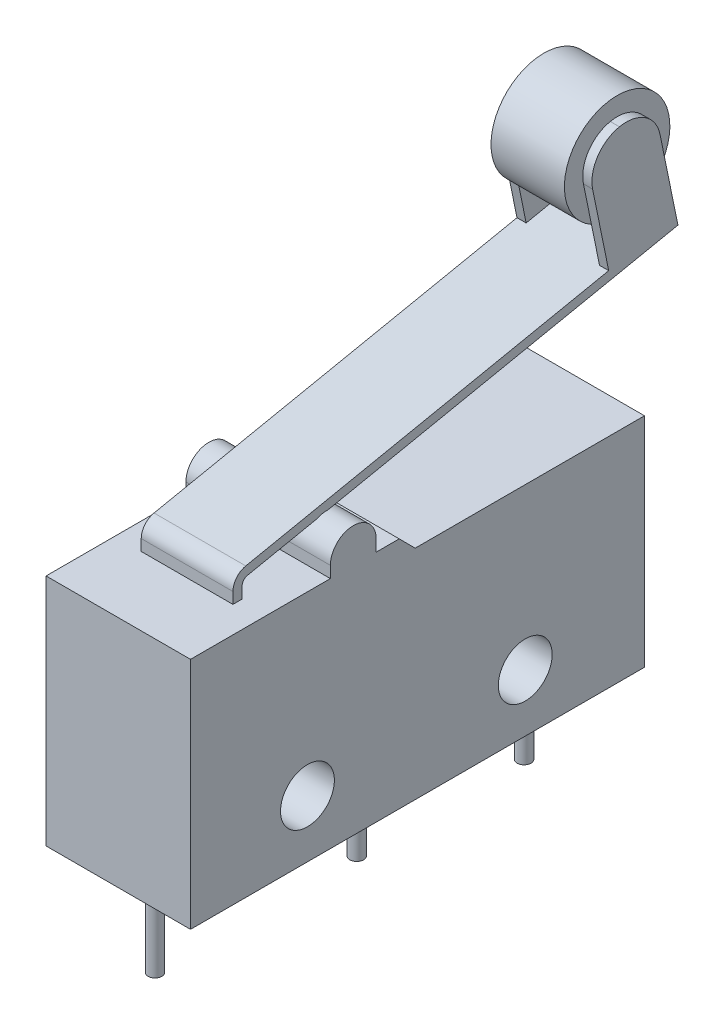
from build123d import *

# Parameters (mm, degrees)
ESQUISSE1_R      = 1.175
EXTRUSION1_DEPTH = 6.3
ESQUISSE2_R      = 0.3
EXTRUSION2_DEPTH = 4
ESQUISSE7_W      = 4
ESQUISSE7_H      = 0.4
ESQUISSE9_W      = 0.4
ESQUISSE9_H      = 3
EXTRUSION3_DEPTH = 5
CONG_1_R         = 1.499
ESQUISSE10_R     = 2.3
EXTRUSION4_DEPTH = 3.2


with BuildPart() as part:
    # Esquisse1 → Extrusion1 (new body)
    with BuildSketch(Plane(origin=(0, 0, 0), x_dir=(0, 0, -1), z_dir=(1, 0, 0))):
        with BuildLine():
            Line((9.8, 9.5), (19.8, 9.5))
            Line((19.8, 9.5), (19.8, 0))
            Line((19.8, 0), (0, 0))
            Line((0, 0), (0, 10.2))
            Line((0, 10.2), (6.1, 10.2))
            Line((6.1, 10.2), (6.1, 10.7))
            ThreePointArc((6.1, 10.7), (7.1, 11.7), (8.1, 10.7))
            Line((8.1, 10.7), (8.1, 10.2))
            Line((8.1, 10.2), (9.102549487, 10.2))
            Line((9.102549487, 10.2), (9.8, 9.5))
        make_face()
        with Locations((14.6, 2.5)):
            Circle(ESQUISSE1_R, mode=Mode.SUBTRACT)
        with Locations((5.1, 2.5)):
            Circle(ESQUISSE1_R, mode=Mode.SUBTRACT)
    extrude(amount=EXTRUSION1_DEPTH)

    # Esquisse2 → Extrusion2 (add)
    with BuildSketch(Plane.XZ):
        with Locations(Location((3.15, -1.6, 0), (0, 0, 90))):  # turned: the seam where the file's is
            Circle(ESQUISSE2_R)
        with Locations(Location((3.15, -10.4, 0), (0, 0, 90))):  # turned: the seam where the file's is
            Circle(ESQUISSE2_R)
        with Locations(Location((3.15, -17.7, 0), (0, 0, 90))):  # turned: the seam where the file's is
            Circle(ESQUISSE2_R)
    extrude(amount=EXTRUSION2_DEPTH)

    # Balayage1: sweep along a path in Esquisse8
    with BuildLine(Plane(origin=(3.15, 0, 0), x_dir=(0, 0, -1), z_dir=(1, 0, 0))) as balayage1_path:
        Line((3.2, 10.2), (3.2, 10.687364871))
        ThreePointArc((3.2, 10.687364871), (3.312633707, 11.003509387), (3.59978942, 11.177219788))
        Line((3.59978942, 11.177219788), (22.368561812, 15.01678431))
    # Esquisse7 → Balayage1 (sweep)
    with BuildSketch(Plane(origin=(0, 10.2, 0), x_dir=(-1, 0, 0), z_dir=(0, 1, 0))):
        with Locations((-3.15, -3.2)):
            Rectangle(ESQUISSE7_W, ESQUISSE7_H)
    sweep(path=balayage1_path.line)

    # Esquisse9 → Extrusion3 (add)
    with BuildSketch(Plane(origin=(0, 10.217352882, 2.090183887), x_dir=(-1, 0, 0), z_dir=(0, 0.979709834, 0.200421159))):
        with Locations((-4.95, -23.4243813)):
            Rectangle(ESQUISSE9_W, ESQUISSE9_H)
        with Locations((-1.35, -23.4243813)):
            Rectangle(ESQUISSE9_W, ESQUISSE9_H)
    extrude(amount=EXTRUSION3_DEPTH)

    # Congé1
    cong_1_edges = [part.edges().sort_by_distance(p)[0] for p in [
        (1.35, 19.510011969, -18.387242281),
        (1.35, 20.111275447, -21.326371784),
        (4.95, 20.111275447, -21.326371784),
        (4.95, 19.510011969, -18.387242281),
    ]]
    fillet(cong_1_edges, radius=CONG_1_R)

    # Esquisse10 → Extrusion4 (add)
    with BuildSketch(Plane(origin=(1.55, 0, 0), x_dir=(0, 0, -1), z_dir=(1, 0, 0))):
        with Locations(Location((20.15723835, 18.342058667, 0), (0, 0, 240.855881524))):  # turned: the seam where the file's is
            Circle(ESQUISSE10_R)
    extrude(amount=EXTRUSION4_DEPTH)


solid = part.part
